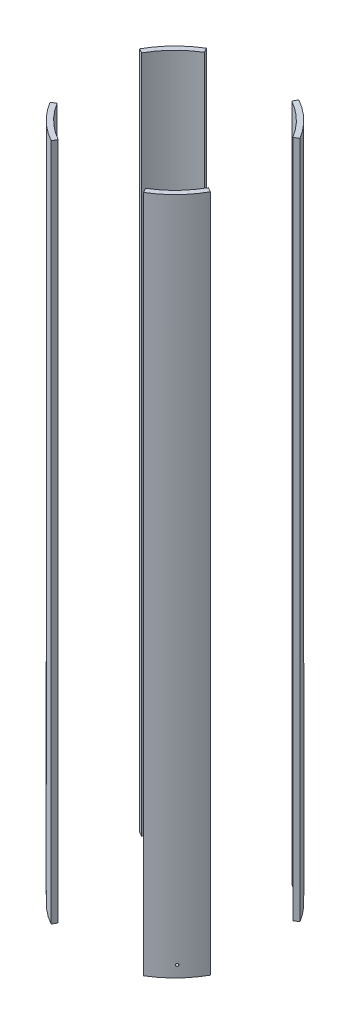
from build123d import *

# Parameters (mm, degrees)
SKETCH2_R               = 88.9
SKETCH2_R_2             = 83.82
BOSS_EXTRUDE1_DEPTH     = 331.184123
CUT_EXTRUDE1_DEPTH      = 332.184123
CUT_EXTRUDE1_DEPTH_BACK = 332.184123
SKETCH5_R               = 1.27
BOLT_HOLES_DEPTH        = 29.911624556
BOLT_PATTERN_COUNT      = 4


with BuildPart() as part:
    # Sketch2 → Boss-Extrude1 (new body, symmetric)
    with BuildSketch(Plane(origin=(0, 0, 0), x_dir=(1, 0, 0), z_dir=(0, 1, 0))):
        Circle(SKETCH2_R)
        Circle(SKETCH2_R_2, mode=Mode.SUBTRACT)
    extrude(amount=BOSS_EXTRUDE1_DEPTH, both=True)

    # Sketch3 → Cut-Extrude1 (cut, two sides)
    with BuildSketch(Plane(origin=(0, 0, 0), x_dir=(1, 0, 0), z_dir=(0, 1, 0))) as cut_extrude1_sk:
        Polygon((169.661755759, -94.300371224), (0, 0), (169.661755759, 101.677593364), align=None)
        Polygon((0, 0), (53.900027233, 96.974944394), (-58.116685864, 96.974944394), align=None)
        Polygon((-123.741299607, 68.777140945), (-123.741299607, -74.157652604), (0, 0), align=None)
        Polygon((-65.840936026, -118.45858783), (0, 0), (70.991745134, -118.45858783), align=None)
    extrude(amount=CUT_EXTRUDE1_DEPTH, mode=Mode.SUBTRACT)
    extrude(cut_extrude1_sk.sketch, amount=-CUT_EXTRUDE1_DEPTH_BACK, mode=Mode.SUBTRACT)

    # Sketch5 → Bolt holes (cut, through all)
    with BuildSketch(Plane(origin=(-56.309218645, 0, 58.175814955), x_dir=(-0.718540152, 0, -0.695485478), z_dir=(0.695485478, 0, -0.718540152))):
        with Locations((0, -320.071623)):
            Circle(SKETCH5_R)
    bolt_holes = extrude(amount=-BOLT_HOLES_DEPTH, mode=Mode.SUBTRACT)

    # Bolt pattern: Bolt holes ×4 about axis
    bolt_pattern_axis = Axis((0, 331.184123, 0), (0, 1, 0))
    for i in range(1, BOLT_PATTERN_COUNT):
        add(bolt_holes.rotate(bolt_pattern_axis, i * 360 / BOLT_PATTERN_COUNT), mode=Mode.SUBTRACT)


solid = part.part
